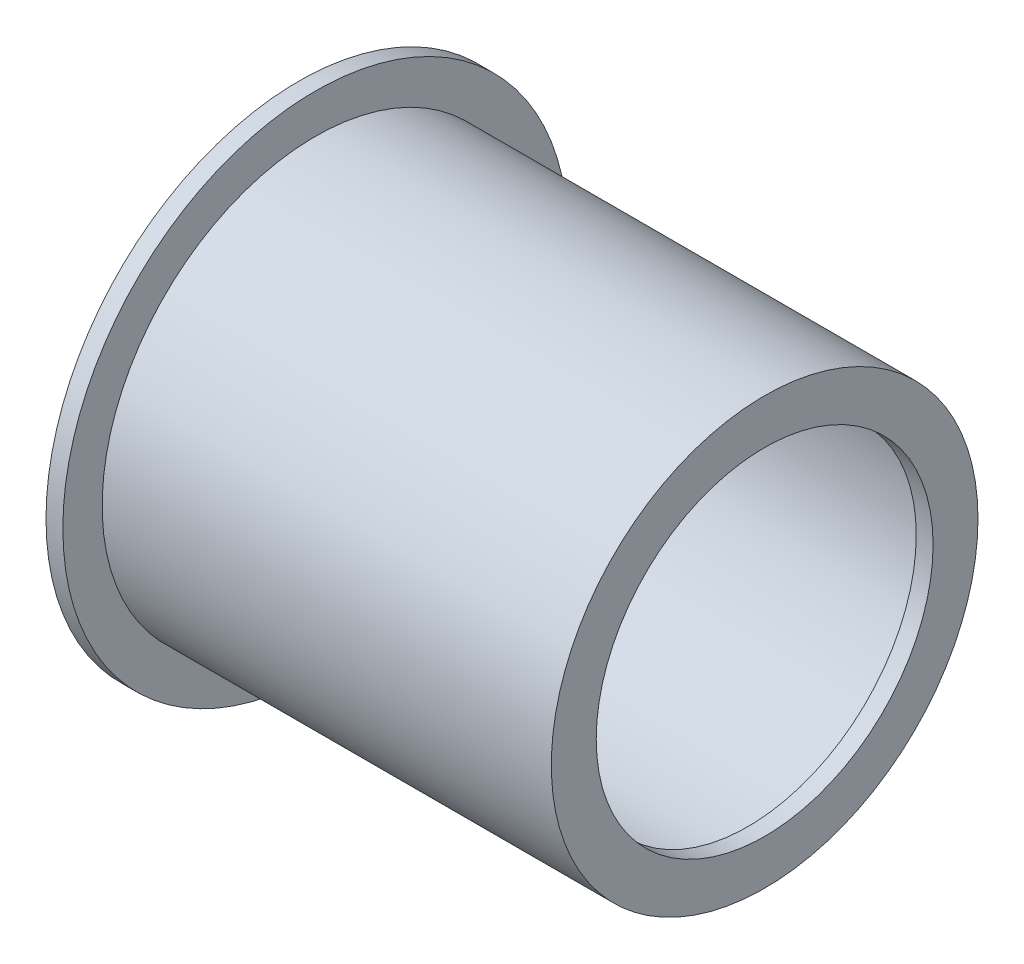
from build123d import *

# Parameters (mm, degrees)
SKETCH2_R           = 35
BOSS_EXTRUDE1_DEPTH = 3


with BuildPart() as part:
    # Sketch1 → Revolve-Thin1 (revolve)
    with BuildSketch(Plane.XY):
        Polygon((-80, 45), (-80, 35), (0, 35), (0, 30), (3, 30), (3, 38), (-77, 38), (-77, 45), align=None)
    revolve(axis=Axis((0, 0, 0), (-1, 0, 0)))

    # Sketch2 → Boss-Extrude1 (add)
    with BuildSketch(Plane.ZY.offset(80)):
        Circle(SKETCH2_R)
    extrude(amount=-BOSS_EXTRUDE1_DEPTH)


solid = part.part
